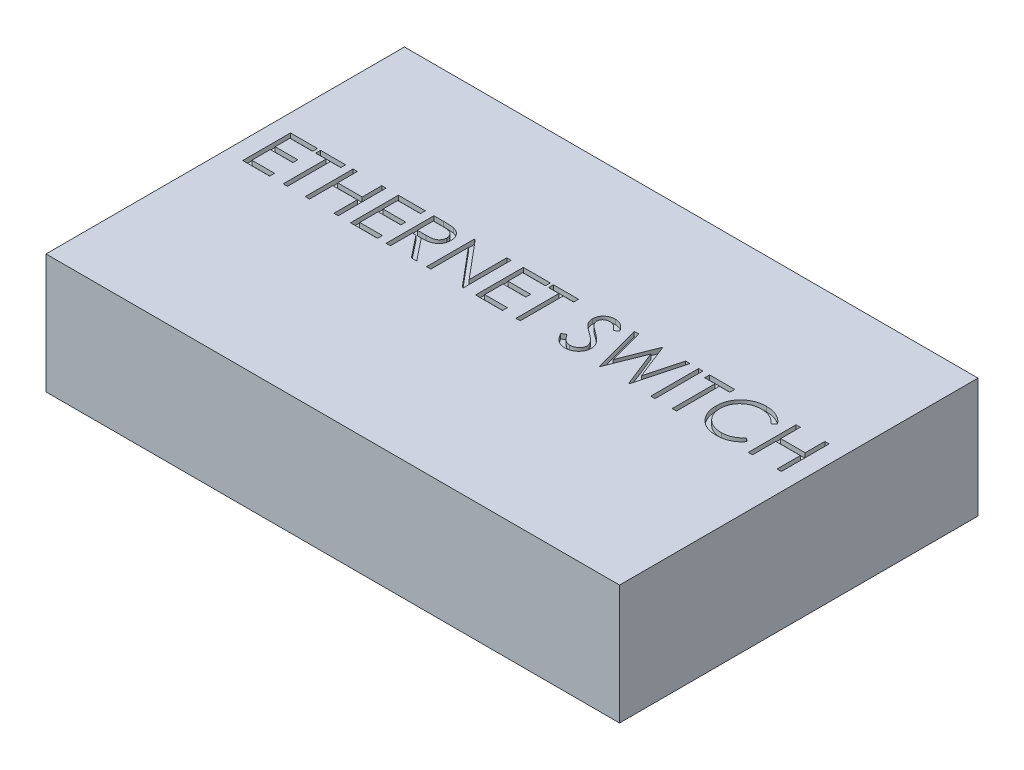
from build123d import *

# Parameters (mm, degrees)
SKETCH1_W           = 120
SKETCH1_H           = 75
BOSS_EXTRUDE1_DEPTH = 25
SKETCH2_W           = 0.897435898
SKETCH2_H           = 10
CUT_EXTRUDE1_DEPTH  = 1


with BuildPart() as part:
    # Sketch1 → Boss-Extrude1 (new body)
    with BuildSketch(Plane(origin=(0, 0, 0), x_dir=(1, 0, 0), z_dir=(0, 1, 0))):
        with Locations((60, 37.5)):
            Rectangle(SKETCH1_W, SKETCH1_H)
    extrude(amount=BOSS_EXTRUDE1_DEPTH)

    # Sketch2 → Cut-Extrude1 (cut)
    with BuildSketch(Plane(origin=(0, 25, 0), x_dir=(1, 0, 0), z_dir=(0, 1, 0))):
        Polygon((3.653846154, 47.5), (9.294871795, 47.5), (9.294871795, 46.474358974), (4.551282051, 46.474358974), (4.551282051, 43.397435897), (9.294871795, 43.397435897), (9.294871795, 42.371794872), (4.551282051, 42.371794872), (4.551282051, 38.525641026), (9.294871795, 38.525641026), (9.294871795, 37.5), (3.653846154, 37.5), align=None)
        Polygon((9.935897436, 46.474358974), (9.935897436, 47.5), (15.192307692, 47.5), (15.192307692, 46.474358974), (13.012820513, 46.474358974), (13.012820513, 37.5), (12.115384615, 37.5), (12.115384615, 46.474358974), align=None)
        Polygon((16.730769231, 47.5), (17.628205128, 47.5), (17.628205128, 43.397435897), (22.756410256, 43.397435897), (22.756410256, 47.5), (23.653846154, 47.5), (23.653846154, 37.5), (22.756410256, 37.5), (22.756410256, 42.371794872), (17.628205128, 42.371794872), (17.628205128, 37.5), (16.730769231, 37.5), align=None)
        Polygon((26.217948718, 47.5), (31.858974359, 47.5), (31.858974359, 46.474358974), (27.115384615, 46.474358974), (27.115384615, 43.397435897), (31.858974359, 43.397435897), (31.858974359, 42.371794872), (27.115384615, 42.371794872), (27.115384615, 38.525641026), (31.858974359, 38.525641026), (31.858974359, 37.5), (26.217948718, 37.5), align=None)
        with BuildLine():
            Line((33.653846154, 47.5), (35.655048077, 47.5))
            add(Edge.make_bspline(
                [(35.655048077, 47.5), (35.788594158, 47.499555469), (36.045017428, 47.498701919), (36.412369629, 47.493942596), (36.746161335, 47.48030158), (37.046218019, 47.46856277), (37.312534176, 47.447157224), (37.545926435, 47.426698232), (37.745319856, 47.399916344), (37.866022289, 47.375043707), (37.920673077, 47.363782051)],
                knots=[0, 0, 0, 0, 1.410062039, 2.707475311, 3.878576406, 4.937260626, 5.877586885, 6.699081471, 7.410979367, 8, 8, 8, 8], degree=3))
            add(Edge.make_bspline(
                [(37.920673077, 47.363782051), (37.99383486, 47.345705579), (38.138597687, 47.309938254), (38.347026447, 47.234339395), (38.545638801, 47.146854753), (38.733609728, 47.044101266), (38.909997703, 46.925316181), (39.076621448, 46.792550117), (39.234237058, 46.646529529), (39.376470287, 46.483572839), (39.510581863, 46.312611383), (39.623692225, 46.127743506), (39.721196452, 45.934424856), (39.798826501, 45.730689377), (39.861334997, 45.518512886), (39.905409966, 45.295973467), (39.931841931, 45.064084967), (39.934532947, 44.905919513), (39.935897436, 44.825721154)],
                knots=[0, 0, 0, 0, 1.027469482, 2.033020251, 3.019912614, 3.986113645, 4.951240523, 5.91722682, 6.890402269, 7.87763091, 8.8651537, 9.85103654, 10.82876324, 11.815024772, 12.821070561, 13.842952187, 14.906261191, 16, 16, 16, 16], degree=3))
            add(Edge.make_bspline(
                [(39.935897436, 44.825721154), (39.931700298, 44.692477998), (39.923510596, 44.43248609), (39.847153157, 44.055169286), (39.722077386, 43.703199815), (39.549725132, 43.37702085), (39.330240916, 43.082990434), (39.066455798, 42.824731991), (38.758222623, 42.608617955), (38.47128172, 42.458752798), (38.217812578, 42.362773059), (38.00914597, 42.295240606), (37.781526034, 42.243063562), (37.53713365, 42.196320328), (37.274951777, 42.161029773), (36.995608807, 42.13518236), (36.698905517, 42.119027935), (36.495079604, 42.116622207), (36.390224359, 42.115384615)],
                knots=[0, 0, 0, 0, 1.260483769, 2.459530307, 3.627416485, 4.787058657, 5.939039949, 7.08810263, 8.267026773, 9.491475466, 10.141966685, 10.831826277, 11.566392101, 12.351337768, 13.187381173, 14.07005841, 15.007169909, 16, 16, 16, 16], degree=3))
            Line((36.390224359, 42.115384615), (40.064102564, 37.5))
            Line((40.064102564, 37.5), (38.954326923, 37.5))
            Line((38.954326923, 37.5), (35.280448718, 42.115384615))
            Line((35.280448718, 42.115384615), (34.551282051, 42.115384615))
            Line((34.551282051, 42.115384615), (34.551282051, 37.5))
            Line((34.551282051, 37.5), (33.653846154, 37.5))
            Line((33.653846154, 37.5), (33.653846154, 47.5))
        make_face()
        with BuildLine():
            Line((34.551282051, 46.474358974), (34.551282051, 43.141025641))
            Line((34.551282051, 43.141025641), (36.382211538, 43.127003205))
            add(Edge.make_bspline(
                [(36.382211538, 43.127003205), (36.467697364, 43.126965386), (36.633393241, 43.126892082), (36.873109427, 43.138302871), (37.096309746, 43.151283781), (37.302140466, 43.171139054), (37.490693539, 43.19672783), (37.661874719, 43.228736356), (37.815963439, 43.266027964), (37.995673549, 43.323746895), (38.196349353, 43.415192661), (38.414439238, 43.548236943), (38.600160203, 43.715577284), (38.757068381, 43.906930015), (38.883152471, 44.117319298), (38.972044055, 44.34422321), (39.028451033, 44.58191349), (39.03510402, 44.745279512), (39.038461538, 44.827724359)],
                knots=[0, 0, 0, 0, 1.146690395, 2.22261258, 3.21895312, 4.145990853, 4.996080663, 5.770904154, 6.481378293, 7.121626537, 8.300444488, 9.431385265, 10.535395872, 11.636531494, 12.74115979, 13.810798291, 14.895190096, 16, 16, 16, 16], degree=3))
            add(Edge.make_bspline(
                [(39.038461538, 44.827724359), (39.035026907, 44.908143141), (39.02822072, 45.067503823), (38.97265281, 45.300806424), (38.878683149, 45.52099771), (38.752048183, 45.727181953), (38.597764884, 45.914341198), (38.416856847, 46.074475921), (38.214270575, 46.206617249), (38.024924294, 46.291058336), (37.855683687, 46.342829345), (37.708741801, 46.379261242), (37.542709008, 46.408531153), (37.356779126, 46.431982755), (37.151745895, 46.452139739), (36.926572607, 46.46571625), (36.682753234, 46.473755861), (36.513762002, 46.474153258), (36.426282051, 46.474358974)],
                knots=[0, 0, 0, 0, 1.101028733, 2.181837193, 3.264309656, 4.369019818, 5.486613113, 6.575447106, 7.666700264, 8.788928104, 9.402425223, 10.0903467, 10.862060571, 11.710948788, 12.657782767, 13.684531032, 14.801375019, 16, 16, 16, 16], degree=3))
            Line((36.426282051, 46.474358974), (34.551282051, 46.474358974))
        make_face(mode=Mode.SUBTRACT)
        Polygon((42.115384615, 37.5), (42.115384615, 47.5), (42.303685897, 47.5), (48.91025641, 39.629407051), (48.91025641, 47.5), (49.807692308, 47.5), (49.807692308, 37.5), (49.603365385, 37.5), (43.012820513, 45.352564103), (43.012820513, 37.5), align=None)
        Polygon((52.371794872, 47.5), (58.012820513, 47.5), (58.012820513, 46.474358974), (53.269230769, 46.474358974), (53.269230769, 43.397435897), (58.012820513, 43.397435897), (58.012820513, 42.371794872), (53.269230769, 42.371794872), (53.269230769, 38.525641026), (58.012820513, 38.525641026), (58.012820513, 37.5), (52.371794872, 37.5), align=None)
        Polygon((58.653846154, 46.474358974), (58.653846154, 47.5), (63.91025641, 47.5), (63.91025641, 46.474358974), (61.730769231, 46.474358974), (61.730769231, 37.5), (60.833333333, 37.5), (60.833333333, 46.474358974), align=None)
        with BuildLine():
            Line((68.269230769, 39.429086538), (69.114583333, 39.935897436))
            add(Edge.make_bspline(
                [(69.114583333, 39.935897436), (69.193206868, 39.804284907), (69.343846527, 39.552120382), (69.595136125, 39.211383124), (69.855515871, 38.921776961), (70.126913967, 38.684986654), (70.407673819, 38.498561264), (70.699628258, 38.366554887), (71.001793431, 38.284223529), (71.207432921, 38.274223282), (71.310096154, 38.269230769)],
                knots=[0, 0, 0, 0, 1.272034388, 2.437168799, 3.508375237, 4.49857839, 5.41946034, 6.295179144, 7.148887113, 8, 8, 8, 8], degree=3))
            add(Edge.make_bspline(
                [(71.310096154, 38.269230769), (71.397772898, 38.271672691), (71.57159225, 38.276513806), (71.827484372, 38.323030383), (72.076003808, 38.394493608), (72.312028487, 38.496839127), (72.532301671, 38.620663372), (72.725463658, 38.770223879), (72.892452553, 38.937670181), (73.029050023, 39.124477766), (73.133850124, 39.325383905), (73.214398891, 39.531600909), (73.259099101, 39.746368247), (73.265832682, 39.890969569), (73.269230769, 39.963942308)],
                knots=[0, 0, 0, 0, 1.095163259, 2.171163733, 3.241058638, 4.321873601, 5.38011039, 6.391990106, 7.366004449, 8.327778327, 9.272591725, 10.192022065, 11.087607919, 12, 12, 12, 12], degree=3))
            add(Edge.make_bspline(
                [(73.269230769, 39.963942308), (73.265018453, 40.047201878), (73.256455429, 40.216456419), (73.184079772, 40.466169713), (73.070224781, 40.713291342), (72.965188656, 40.8661521), (72.910657051, 40.945512821)],
                knots=[0, 0, 0, 0, 0.938893495, 1.908633276, 2.914225137, 4, 4, 4, 4], degree=3))
            add(Edge.make_bspline(
                [(72.910657051, 40.945512821), (72.865883868, 41.002789459), (72.77188817, 41.123034598), (72.610295277, 41.302020985), (72.420677807, 41.486645039), (72.209524793, 41.683956631), (71.96914454, 41.884778907), (71.707065927, 42.098688272), (71.416597758, 42.317549921), (71.212884911, 42.46432868), (71.107772436, 42.540064103)],
                knots=[0, 0, 0, 0, 0.722233717, 1.516239348, 2.393582979, 3.351407094, 4.387010283, 5.505090956, 6.712668013, 8, 8, 8, 8], degree=3))
            add(Edge.make_bspline(
                [(71.107772436, 42.540064103), (71.002561018, 42.615002924), (70.801404799, 42.758280245), (70.520094564, 42.970921057), (70.268538956, 43.165332112), (70.047856051, 43.343343575), (69.858142917, 43.504979589), (69.6979046, 43.648687987), (69.571223008, 43.778355303), (69.500778492, 43.862473423), (69.469150641, 43.900240385)],
                knots=[0, 0, 0, 0, 1.452282411, 2.77665338, 3.964542531, 5.026858415, 5.96415736, 6.766646006, 7.446254459, 8, 8, 8, 8], degree=3))
            add(Edge.make_bspline(
                [(69.469150641, 43.900240385), (69.424943369, 43.95910049), (69.338003835, 44.074856786), (69.22324382, 44.255784951), (69.125703355, 44.440994281), (69.049239549, 44.630982466), (68.984850352, 44.823082262), (68.941541978, 45.019800107), (68.914423702, 45.220253303), (68.911646597, 45.355149019), (68.91025641, 45.422676282)],
                knots=[0, 0, 0, 0, 1.068054152, 2.10047183, 3.106115577, 4.101338837, 5.06977816, 6.043150881, 7.020423561, 8, 8, 8, 8], degree=3))
            add(Edge.make_bspline(
                [(68.91025641, 45.422676282), (68.913985579, 45.528475638), (68.921364208, 45.737812963), (68.983765685, 46.043615336), (69.082259667, 46.335576528), (69.220245061, 46.610806053), (69.398123212, 46.862137427), (69.603968853, 47.092461675), (69.849144528, 47.286086196), (70.118152023, 47.455263505), (70.412598801, 47.587680435), (70.721144239, 47.687568949), (71.044278731, 47.744166828), (71.26314483, 47.752289014), (71.374198718, 47.756410256)],
                knots=[0, 0, 0, 0, 1.005424448, 1.989358655, 2.955360095, 3.929531133, 4.905563448, 5.876582895, 6.856512386, 7.866279853, 8.892233794, 9.918561126, 10.94386622, 12, 12, 12, 12], degree=3))
            add(Edge.make_bspline(
                [(71.374198718, 47.756410256), (71.492039005, 47.752345823), (71.726385724, 47.744262963), (72.071097768, 47.673984302), (72.402985529, 47.557696668), (72.669966286, 47.425729074), (72.878917033, 47.293925029), (73.038267698, 47.173868388), (73.199746129, 47.035653792), (73.364654857, 46.878913089), (73.530199598, 46.702208086), (73.698838033, 46.506748975), (73.870964515, 46.293730244), (73.981695544, 46.141660242), (74.038461538, 46.063701923)],
                knots=[0, 0, 0, 0, 1.286793592, 2.559021753, 3.825965368, 5.121522368, 5.803751409, 6.523245864, 7.299691795, 8.125521123, 9.008227632, 9.944561021, 10.946284179, 12, 12, 12, 12], degree=3))
            Line((74.038461538, 46.063701923), (73.227163462, 45.448717949))
            add(Edge.make_bspline(
                [(73.227163462, 45.448717949), (73.178175083, 45.511828493), (73.08383492, 45.633364645), (72.940607815, 45.803568404), (72.805611678, 45.95904406), (72.672610536, 46.094087282), (72.548628731, 46.216093378), (72.428294325, 46.320549826), (72.313339036, 46.408480098), (72.168433577, 46.502318841), (71.986382953, 46.595337423), (71.757855706, 46.674049074), (71.519037778, 46.721349251), (71.356381688, 46.727603216), (71.274038462, 46.730769231)],
                knots=[0, 0, 0, 0, 1.181633172, 2.275549214, 3.290209073, 4.226197932, 5.078386478, 5.862611352, 6.581680152, 7.217281963, 8.414376989, 9.595101626, 10.782541182, 12, 12, 12, 12], degree=3))
            add(Edge.make_bspline(
                [(71.274038462, 46.730769231), (71.170734112, 46.727307231), (70.971521405, 46.72063109), (70.688692159, 46.647716847), (70.434138087, 46.532911531), (70.215416473, 46.372011594), (70.033310824, 46.181380186), (69.901580942, 45.962012029), (69.822294758, 45.719776593), (69.812619673, 45.550800432), (69.807692308, 45.46474359)],
                knots=[0, 0, 0, 0, 1.14458467, 2.207223713, 3.21896685, 4.227309161, 5.202851033, 6.127160689, 7.046193047, 8, 8, 8, 8], degree=3))
            add(Edge.make_bspline(
                [(69.807692308, 45.46474359), (69.808815527, 45.411167937), (69.811063801, 45.303929024), (69.842420366, 45.14549639), (69.882704163, 44.987463992), (69.946540254, 44.830542326), (70.034669693, 44.671987015), (70.150398767, 44.509067765), (70.296151087, 44.340348597), (70.407799694, 44.230613243), (70.466746795, 44.172676282)],
                knots=[0, 0, 0, 0, 0.858281714, 1.717966888, 2.583508476, 3.4729293, 4.427298488, 5.488583878, 6.674047936, 8, 8, 8, 8], degree=3))
            add(Edge.make_bspline(
                [(70.466746795, 44.172676282), (70.48863643, 44.153141923), (70.540641194, 44.106732756), (70.635715267, 44.030754811), (70.761266119, 43.937032605), (70.914015265, 43.821068843), (71.096779156, 43.68655038), (71.309577888, 43.535197203), (71.55003941, 43.362095891), (71.720673456, 43.241074346), (71.810897436, 43.177083333)],
                knots=[0, 0, 0, 0, 0.420754252, 0.999615792, 1.744751191, 2.668019286, 3.750313428, 4.999500688, 6.413464383, 8, 8, 8, 8], degree=3))
            add(Edge.make_bspline(
                [(71.810897436, 43.177083333), (71.919428617, 43.09810802), (72.129584206, 42.945183272), (72.428605863, 42.715424187), (72.699731029, 42.490716276), (72.943911611, 42.272494542), (73.163559921, 42.062414276), (73.356239123, 41.857948047), (73.523912495, 41.660560696), (73.704424548, 41.407496194), (73.888875461, 41.096693096), (74.047279768, 40.715898129), (74.14716076, 40.333622928), (74.160222233, 40.076689109), (74.166666667, 39.949919872)],
                knots=[0, 0, 0, 0, 1.163667725, 2.253281268, 3.268753668, 4.215851969, 5.092017293, 5.902905408, 6.650798638, 7.335211899, 8.59617414, 9.77448103, 10.901945474, 12, 12, 12, 12], degree=3))
            add(Edge.make_bspline(
                [(74.166666667, 39.949919872), (74.164789129, 39.8602674), (74.161070515, 39.682703447), (74.118325047, 39.421974656), (74.055697432, 39.1687436), (73.961305335, 38.926140421), (73.846096311, 38.689726814), (73.699907032, 38.465704241), (73.530456504, 38.249114531), (73.336074319, 38.045733127), (73.12337174, 37.85902971), (72.898561184, 37.692946677), (72.66127469, 37.554465753), (72.4127995, 37.441463347), (72.153078538, 37.353081869), (71.882199155, 37.2890451), (71.599714837, 37.249743068), (71.407713462, 37.24566375), (71.310096154, 37.243589744)],
                knots=[0, 0, 0, 0, 0.983748083, 1.948392443, 2.894712957, 3.844097841, 4.80183111, 5.778335162, 6.776009319, 7.81870978, 8.863265674, 9.881300176, 10.883814829, 11.87499822, 12.874611388, 13.892143829, 14.928324115, 16, 16, 16, 16], degree=3))
            add(Edge.make_bspline(
                [(71.310096154, 37.243589744), (71.234566602, 37.245050262), (71.084458717, 37.247952906), (70.862431626, 37.273613708), (70.644889942, 37.309919718), (70.434563422, 37.367559918), (70.228742246, 37.437494138), (70.028321576, 37.52360366), (69.833204279, 37.626795664), (69.642296899, 37.744781448), (69.456084972, 37.88208929), (69.276315064, 38.042013566), (69.097088819, 38.22014358), (68.923696258, 38.421316618), (68.752630132, 38.642282569), (68.587263247, 38.885108807), (68.424172626, 39.148472675), (68.321842717, 39.333801492), (68.269230769, 39.429086538)],
                knots=[0, 0, 0, 0, 0.915332311, 1.819136955, 2.706846663, 3.586547465, 4.459518054, 5.340707479, 6.227863349, 7.133153174, 8.059268498, 9.028702269, 10.047606654, 11.120612155, 12.245963614, 13.433783089, 14.680604001, 16, 16, 16, 16], degree=3))
        make_face()
        Polygon((75.576923077, 47.5), (76.502403846, 47.5), (78.461538462, 40.16025641), (81.370192308, 47.5), (81.500400641, 47.5), (84.358974359, 40.216346154), (86.326121795, 47.5), (87.243589744, 47.5), (84.547275641, 37.5), (84.419070513, 37.5), (81.41025641, 45.144230769), (78.369391026, 37.5), (78.239182692, 37.5), align=None)
        with Locations((89.487179487, 42.5)):
            Rectangle(SKETCH2_W, SKETCH2_H)
        Polygon((91.346153846, 46.474358974), (91.346153846, 47.5), (96.602564103, 47.5), (96.602564103, 46.474358974), (94.423076923, 46.474358974), (94.423076923, 37.5), (93.525641026, 37.5), (93.525641026, 46.474358974), align=None)
        with BuildLine():
            Line((107.371794872, 45.665064103), (106.586538462, 45.064102564))
            add(Edge.make_bspline(
                [(106.586538462, 45.064102564), (106.530521638, 45.130862478), (106.419243218, 45.263482237), (106.240216925, 45.449709507), (106.053640803, 45.624181683), (105.859586171, 45.78772991), (105.654560115, 45.934634955), (105.443529262, 46.072552392), (105.222963418, 46.1961745), (104.917958462, 46.346068746), (104.51896461, 46.502486332), (104.016693641, 46.633638422), (103.492376217, 46.717127495), (103.134668789, 46.726169899), (102.952724359, 46.730769231)],
                knots=[0, 0, 0, 0, 0.757959112, 1.505699292, 2.245454638, 2.979532153, 3.711538275, 4.438200793, 5.171680507, 5.909471876, 7.393775596, 8.890124382, 10.418191784, 12, 12, 12, 12], degree=3))
            add(Edge.make_bspline(
                [(102.952724359, 46.730769231), (102.852486361, 46.729615052), (102.652940668, 46.727317407), (102.356802172, 46.697005621), (102.066193455, 46.654402163), (101.781303551, 46.591186954), (101.502495098, 46.511265185), (101.227945378, 46.415764003), (100.961629379, 46.297607317), (100.699862984, 46.167012289), (100.449065238, 46.019505304), (100.211765101, 45.858610013), (99.98882805, 45.68612688), (99.78007773, 45.501409433), (99.585300735, 45.305289546), (99.405908418, 45.095677142), (99.242521532, 44.87324236), (99.09190146, 44.640918339), (98.957007936, 44.399381791), (98.844065423, 44.147738733), (98.744050789, 43.890298438), (98.664910095, 43.624152265), (98.602268619, 43.351172934), (98.559046724, 43.070627825), (98.529079663, 42.783103026), (98.526793443, 42.588219276), (98.525641026, 42.489983974)],
                knots=[0, 0, 0, 0, 1.054917814, 2.100044995, 3.131103042, 4.146048494, 5.169673617, 6.183595914, 7.203665975, 8.234915748, 9.262203917, 10.264457458, 11.251630812, 12.227803204, 13.197192746, 14.159520551, 15.12972552, 16.100847026, 17.073214652, 18.039054194, 19.002613845, 19.979014051, 20.95965708, 21.949030935, 22.966165397, 24, 24, 24, 24], degree=3))
            add(Edge.make_bspline(
                [(98.525641026, 42.489983974), (98.529246223, 42.342180203), (98.536324549, 42.051987104), (98.59931979, 41.626928216), (98.695048622, 41.219726291), (98.838521699, 40.832926742), (99.015433272, 40.461760004), (99.238977876, 40.112506138), (99.497882269, 39.779887382), (99.795809181, 39.471764674), (100.122682941, 39.190296887), (100.47339126, 38.942438083), (100.847060654, 38.735824133), (101.239565312, 38.563892857), (101.653925637, 38.431730778), (102.089396501, 38.338690426), (102.545030773, 38.277998481), (102.856371916, 38.272187944), (103.014823718, 38.269230769)],
                knots=[0, 0, 0, 0, 1.029171465, 2.020641659, 2.987623507, 3.938342917, 4.889210282, 5.84687017, 6.821220943, 7.821438502, 8.827599549, 9.822697543, 10.807740252, 11.797342354, 12.80366471, 13.83203677, 14.896651826, 16, 16, 16, 16], degree=3))
            add(Edge.make_bspline(
                [(103.014823718, 38.269230769), (103.189402829, 38.274055854), (103.533016283, 38.283552776), (104.03692493, 38.364007773), (104.519312832, 38.494458967), (104.980205936, 38.677024459), (105.418304925, 38.914353853), (105.834295383, 39.202062075), (106.228528442, 39.542885882), (106.465589248, 39.803123392), (106.586538462, 39.935897436)],
                knots=[0, 0, 0, 0, 1.028121516, 2.023589091, 2.998037872, 3.967518031, 4.937445131, 5.927275754, 6.942489185, 8, 8, 8, 8], degree=3))
            Line((106.586538462, 39.935897436), (107.371794872, 39.340945513))
            add(Edge.make_bspline(
                [(107.371794872, 39.340945513), (107.308600272, 39.259407079), (107.182513771, 39.096720775), (106.978348009, 38.867373033), (106.763270016, 38.651647217), (106.535682273, 38.451282585), (106.298202869, 38.262269826), (106.04656769, 38.08997888), (105.78408474, 37.932004925), (105.511643372, 37.787356569), (105.22953305, 37.659021578), (104.938091807, 37.54915367), (104.638575877, 37.454511128), (104.330971567, 37.376648452), (104.014640834, 37.315873926), (103.690725193, 37.275246284), (103.35852555, 37.247412243), (103.134407204, 37.24487534), (103.020833333, 37.243589744)],
                knots=[0, 0, 0, 0, 0.986787822, 1.968848986, 2.935600012, 3.899624008, 4.868462664, 5.837806735, 6.815139263, 7.798259679, 8.787526145, 9.778297419, 10.776456485, 11.791383307, 12.812564526, 13.85620153, 14.913611965, 16, 16, 16, 16], degree=3))
            add(Edge.make_bspline(
                [(103.020833333, 37.243589744), (102.913279999, 37.244338294), (102.700606599, 37.245818459), (102.386610165, 37.26979608), (102.080925649, 37.302509614), (101.784426718, 37.351767132), (101.495495361, 37.409893817), (101.216750833, 37.487811693), (100.945450232, 37.575095027), (100.682683545, 37.677680703), (100.42822726, 37.793441225), (100.182902084, 37.92427425), (99.946820849, 38.069079578), (99.717662503, 38.224665322), (99.498812264, 38.396029041), (99.288373621, 38.580790854), (99.085166546, 38.778328028), (98.959444588, 38.920770466), (98.896233974, 38.992387821)],
                knots=[0, 0, 0, 0, 1.114604814, 2.203992996, 3.262667896, 4.300477797, 5.318619304, 6.316056647, 7.298880507, 8.271930387, 9.238335007, 10.195173496, 11.151986948, 12.108099108, 13.064862484, 14.031167946, 15.010108607, 16, 16, 16, 16], degree=3))
            add(Edge.make_bspline(
                [(98.896233974, 38.992387821), (98.794989279, 39.116791217), (98.593722202, 39.364096104), (98.336220249, 39.764913194), (98.115798663, 40.18339379), (97.937581746, 40.621736444), (97.798259651, 41.07895755), (97.701741951, 41.555287592), (97.639023081, 42.050281712), (97.631850828, 42.386958251), (97.628205128, 42.558092949)],
                knots=[0, 0, 0, 0, 0.994628077, 1.977248131, 2.950237994, 3.925870899, 4.908910175, 5.911660606, 6.938484602, 8, 8, 8, 8], degree=3))
            add(Edge.make_bspline(
                [(97.628205128, 42.558092949), (97.632648538, 42.737965673), (97.64139067, 43.091854029), (97.715664372, 43.611208181), (97.835146647, 44.108783607), (98.004852043, 44.583651448), (98.220010189, 45.038309392), (98.485800514, 45.469284263), (98.799135207, 45.879332262), (99.157556828, 46.262231551), (99.550606358, 46.612343987), (99.971517255, 46.920361712), (100.419465675, 47.176697472), (100.889516679, 47.390972222), (101.385190055, 47.555670688), (101.905428253, 47.670965507), (102.449253724, 47.742728697), (102.820289226, 47.751800719), (103.008814103, 47.756410256)],
                knots=[0, 0, 0, 0, 1.032925535, 2.032216505, 3.007276963, 3.968222605, 4.92396291, 5.891752235, 6.871517503, 7.883894988, 8.900124299, 9.891468569, 10.874487609, 11.85992873, 12.854644235, 13.869047385, 14.917252991, 16, 16, 16, 16], degree=3))
            add(Edge.make_bspline(
                [(103.008814103, 47.756410256), (103.123712594, 47.755032719), (103.351142586, 47.752306022), (103.687578736, 47.725717044), (104.015128241, 47.681392455), (104.334016762, 47.621060827), (104.645795665, 47.546182766), (104.948082067, 47.448639056), (105.242649744, 47.337106109), (105.52764091, 47.20865335), (105.801688197, 47.06446266), (106.064706249, 46.906132307), (106.314605846, 46.733858577), (106.553145413, 46.549106647), (106.776334587, 46.347967906), (106.99051024, 46.135974775), (107.188399035, 45.907020992), (107.310551021, 45.745864038), (107.371794872, 45.665064103)],
                knots=[0, 0, 0, 0, 1.096760587, 2.17092713, 3.219439832, 4.250915756, 5.268269357, 6.278326846, 7.281116186, 8.274029601, 9.260640565, 10.235837813, 11.203064059, 12.156899882, 13.114053108, 14.069676657, 15.032185724, 16, 16, 16, 16], degree=3))
        make_face()
        Polygon((109.423076923, 47.5), (110.320512821, 47.5), (110.320512821, 43.397435897), (115.448717949, 43.397435897), (115.448717949, 47.5), (116.346153846, 47.5), (116.346153846, 37.5), (115.448717949, 37.5), (115.448717949, 42.371794872), (110.320512821, 42.371794872), (110.320512821, 37.5), (109.423076923, 37.5), align=None)
    extrude(amount=-CUT_EXTRUDE1_DEPTH, mode=Mode.SUBTRACT)


solid = part.part
